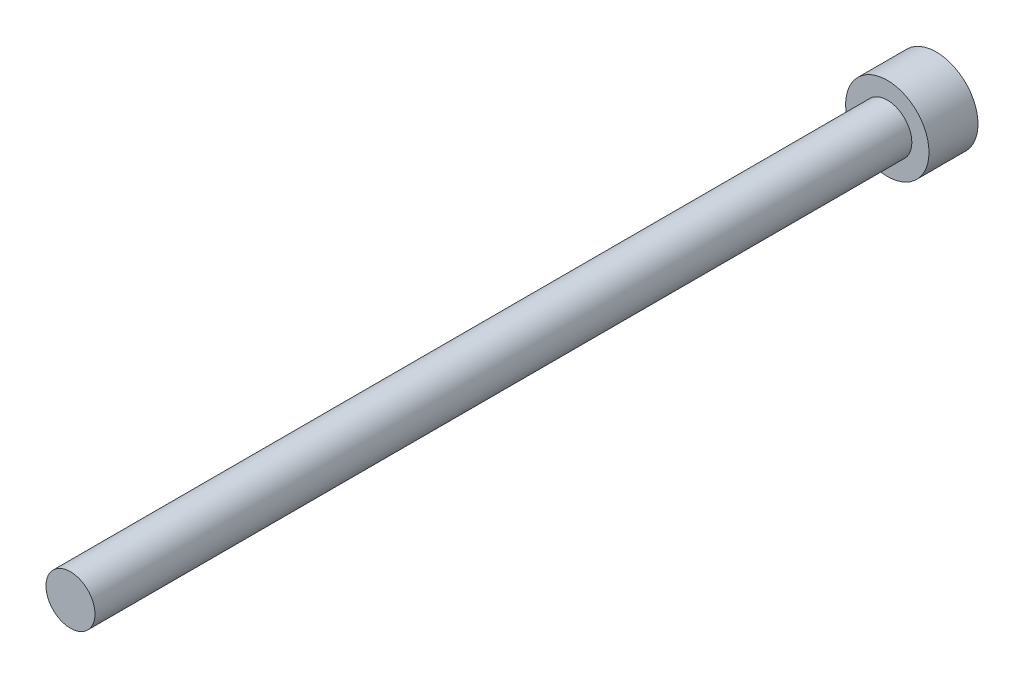
from build123d import *

# Parameters (mm, degrees)
SKETCH_1_R      = 5.1
EXTRUDE_1_DEPTH = 6
SKETCH_2_R      = 3
EXTRUDE_2_DEPTH = 100


with BuildPart() as part:
    # 草图1 → 凸台-拉伸1 (new body)
    with BuildSketch(Plane.XY):
        Circle(SKETCH_1_R)
    extrude(amount=EXTRUDE_1_DEPTH)

    # 草图2 → 凸台-拉伸2 (add)
    with BuildSketch(Plane.XY.offset(6)):
        Circle(SKETCH_2_R)
    extrude(amount=EXTRUDE_2_DEPTH)


solid = part.part
